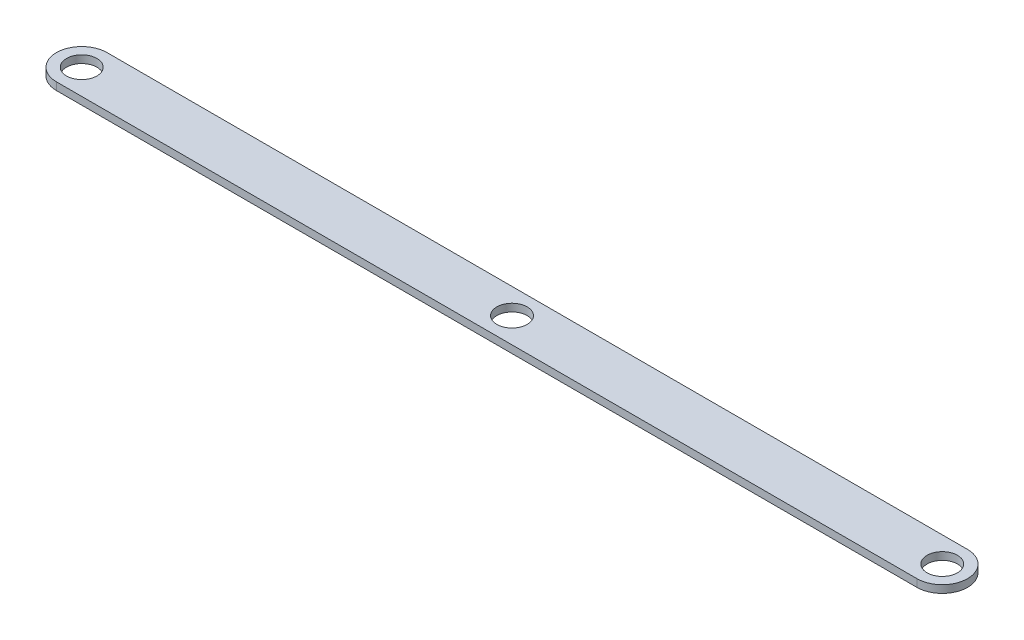
from build123d import *

# Parameters (mm, degrees)
SKETCH1_R           = 6
BOSS_EXTRUDE1_DEPTH = 3


with BuildPart() as part:
    # Sketch1 → Boss-Extrude1 (new body)
    with BuildSketch(Plane(origin=(0, 0, 0), x_dir=(1, 0, 0), z_dir=(0, 1, 0))):
        with BuildLine():
            Line((-62.687563754, 15.857142857), (277.312436246, 15.857142857))
            ThreePointArc((277.312436246, 15.857142857), (287.312436246, 5.857142857), (277.312436246, -4.142857143))
            Line((277.312436246, -4.142857143), (-62.687563754, -4.142857143))
            ThreePointArc((-62.687563754, -4.142857143), (-72.687563754, 5.857142857), (-62.687563754, 15.857142857))
        make_face()
        with Locations((-62.687563754, 5.857142857)):
            Circle(SKETCH1_R, mode=Mode.SUBTRACT)
        with Locations((277.312436246, 5.857142857)):
            Circle(SKETCH1_R, mode=Mode.SUBTRACT)
        with Locations((107.312436246, 5.857142857)):
            Circle(SKETCH1_R, mode=Mode.SUBTRACT)
    extrude(amount=BOSS_EXTRUDE1_DEPTH)


solid = part.part
